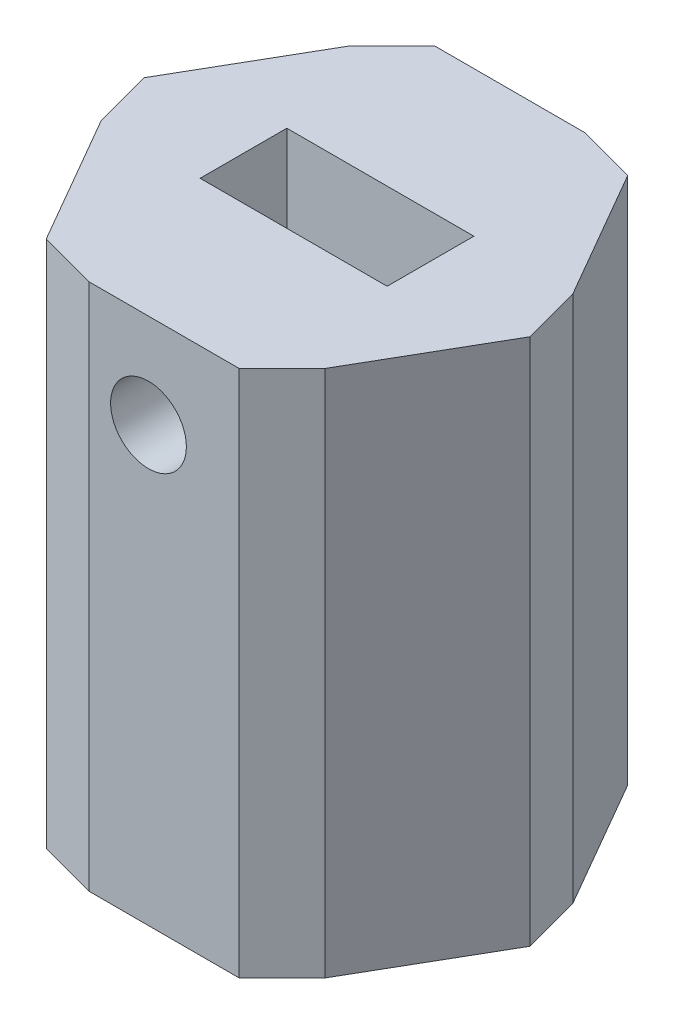
from build123d import *
from OCP.BRepFilletAPI import BRepFilletAPI_MakeChamfer

# Parameters (mm, degrees)
BOSS_EXTRUDE1_DEPTH         = 35.56
SKETCH2_W                   = 12.59949555
SKETCH2_H                   = 5.842
CUT_EXTRUDE1_DEPTH          = 12.7
CUT_EXTRUDE2_DEPTH          = 12.7
F_1_4_20_TAPPED_HOLE1_D     = 5.1054
F_1_4_20_TAPPED_HOLE1_DEPTH = 14.086183098
F_1_4_20_TAPPED_HOLE1_TIP   = 1.533816902
CHAMFER1_SIZE               = 1.2192
CHAMFER1_SIZE2              = 3.330916345


with BuildPart() as part:
    # Sketch1 → Boss-Extrude1 (new body)
    with BuildSketch(Plane(origin=(0, 0, 0), x_dir=(1, 0, 0), z_dir=(0, 1, 0))):
        Polygon((-14.664696837, 0), (-7.332348419, -12.7), (7.332348419, -12.7), (14.664696837, 0), (7.332348419, 12.7), (-7.332348419, 12.7), align=None)
    extrude(amount=BOSS_EXTRUDE1_DEPTH)

    # Sketch2 → Cut-Extrude1 (cut)
    with BuildSketch(Plane(origin=(0, 35.56, 0), x_dir=(1, 0, 0), z_dir=(0, 1, 0))):
        Rectangle(SKETCH2_W, SKETCH2_H)
    extrude(amount=-CUT_EXTRUDE1_DEPTH, mode=Mode.SUBTRACT)

    # Sketch3 → Cut-Extrude2 (cut)
    with BuildSketch(Plane.XZ):
        Polygon((0, 6.465784407), (-6.465784407, 0), (0, -6.465784407), (6.465784407, 0), align=None)
    extrude(amount=-CUT_EXTRUDE2_DEPTH, mode=Mode.SUBTRACT)

    # 1/4-20 Tapped Hole1
    with Locations(Plane.XY.offset(12.7)):
        with Locations((0, 29.21)):
            Hole(F_1_4_20_TAPPED_HOLE1_D / 2, depth=F_1_4_20_TAPPED_HOLE1_DEPTH)
            with Locations((0, 0, -(F_1_4_20_TAPPED_HOLE1_DEPTH + F_1_4_20_TAPPED_HOLE1_TIP / 2))):  # 118° drill point
                Cone(0, F_1_4_20_TAPPED_HOLE1_D / 2, F_1_4_20_TAPPED_HOLE1_TIP, mode=Mode.SUBTRACT)

    # Chamfer1: one chamfer whose edges measure the first distance from different faces: ONE call of the kernel's chamfer builder (chamfer() names one face for all edges)
    chamfer1_edges_1 = [part.edges().sort_by_distance(p)[0] for p in [
        (-7.332348419, 17.78, -12.7),
    ]]
    chamfer1_side_1 = [part.faces().sort_by_distance(p)[0] for p in [
        (0, 17.78, -12.7),
    ]]
    chamfer1_edges_2 = [part.edges().sort_by_distance(p)[0] for p in [
        (7.332348419, 17.78, -12.7),
    ]]
    chamfer1_side_2 = [part.faces().sort_by_distance(p)[0] for p in [
        (10.998522628, 17.78, -6.35),
    ]]
    chamfer1_edges_3 = [part.edges().sort_by_distance(p)[0] for p in [
        (14.664696837, 17.78, 0),
    ]]
    chamfer1_side_3 = [part.faces().sort_by_distance(p)[0] for p in [
        (10.998522628, 17.78, 6.35),
    ]]
    chamfer1_edges_4 = [part.edges().sort_by_distance(p)[0] for p in [
        (7.332348419, 17.78, 12.7),
    ]]
    chamfer1_side_4 = [part.faces().sort_by_distance(p)[0] for p in [
        (0, 17.312960636, 12.7),
    ]]
    chamfer1_edges_5 = [part.edges().sort_by_distance(p)[0] for p in [
        (-7.332348419, 17.78, 12.7),
    ]]
    chamfer1_side_5 = [part.faces().sort_by_distance(p)[0] for p in [
        (-10.998522628, 17.78, 6.35),
    ]]
    chamfer1_edges_6 = [part.edges().sort_by_distance(p)[0] for p in [
        (-14.664696837, 17.78, 0),
    ]]
    chamfer1_side_6 = [part.faces().sort_by_distance(p)[0] for p in [
        (-10.998522628, 17.78, -6.35),
    ]]
    chamfer1_edges_7 = [part.edges().sort_by_distance(p)[0] for p in [
        (0, 6.35, -6.465784407),
        (-6.465784407, 6.35, 0),
        (0, 6.35, 6.465784407),
        (6.465784407, 6.35, 0),
    ]]
    chamfer1 = BRepFilletAPI_MakeChamfer(part.part.solid().wrapped)
    for e in chamfer1_edges_1:
        chamfer1.Add(CHAMFER1_SIZE, CHAMFER1_SIZE2, e.wrapped, chamfer1_side_1[0].wrapped)  # the first distance lies on this face
    for e in chamfer1_edges_2:
        chamfer1.Add(CHAMFER1_SIZE, CHAMFER1_SIZE2, e.wrapped, chamfer1_side_2[0].wrapped)  # the first distance lies on this face
    for e in chamfer1_edges_3:
        chamfer1.Add(CHAMFER1_SIZE, CHAMFER1_SIZE2, e.wrapped, chamfer1_side_3[0].wrapped)  # the first distance lies on this face
    for e in chamfer1_edges_4:
        chamfer1.Add(CHAMFER1_SIZE, CHAMFER1_SIZE2, e.wrapped, chamfer1_side_4[0].wrapped)  # the first distance lies on this face
    for e in chamfer1_edges_5:
        chamfer1.Add(CHAMFER1_SIZE, CHAMFER1_SIZE2, e.wrapped, chamfer1_side_5[0].wrapped)  # the first distance lies on this face
    for e in chamfer1_edges_6:
        chamfer1.Add(CHAMFER1_SIZE, CHAMFER1_SIZE2, e.wrapped, chamfer1_side_6[0].wrapped)  # the first distance lies on this face
    for e in chamfer1_edges_7:
        chamfer1.Add(CHAMFER1_SIZE, e.wrapped)
    add(Compound.cast(chamfer1.Shape()), mode=Mode.REPLACE)


solid = part.part
